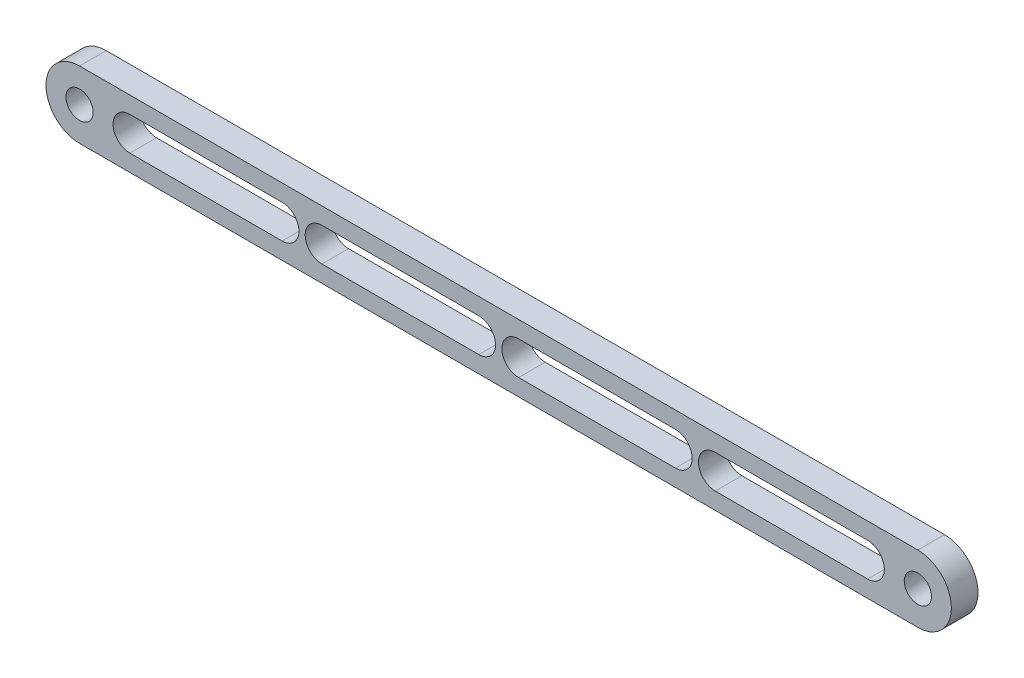
from build123d import *

# Parameters (mm, degrees)
SKETCH1_R           = 3.25
BOSS_EXTRUDE1_DEPTH = 6.35


with BuildPart() as part:
    # Sketch1 → Boss-Extrude1 (new body)
    with BuildSketch(Plane.XY.offset(6.35)):
        with BuildLine():
            Line((200, 8), (0, 8))
            ThreePointArc((0, 8), (-8, 0), (0, -8))
            Line((0, -8), (200, -8))
            ThreePointArc((200, -8), (208, 0), (200, 8))
        make_face()
        with Locations((200, 0)):
            Circle(SKETCH1_R, mode=Mode.SUBTRACT)
        Circle(SKETCH1_R, mode=Mode.SUBTRACT)
        with BuildLine():
            Line((104.75, 4), (142.160898385, 4))
            ThreePointArc((142.160898385, 4), (146.160898385, 0), (142.160898385, -4))
            Line((142.160898385, -4), (104.75, -4))
            ThreePointArc((104.75, -4), (100.75, 0), (104.75, 4))
        make_face(mode=Mode.SUBTRACT)
        with BuildLine():
            Line((12, 4), (48.339101615, 4))
            ThreePointArc((48.339101615, 4), (52.339101615, 0), (48.339101615, -4))
            Line((48.339101615, -4), (12, -4))
            ThreePointArc((12, -4), (8, 0), (12, 4))
        make_face(mode=Mode.SUBTRACT)
        with BuildLine():
            Line((57.839101615, 4), (95.25, 4))
            ThreePointArc((95.25, 4), (99.25, 0), (95.25, -4))
            Line((95.25, -4), (57.839101615, -4))
            ThreePointArc((57.839101615, -4), (53.839101615, 0), (57.839101615, 4))
        make_face(mode=Mode.SUBTRACT)
        with BuildLine():
            Line((188, -4), (151.660898385, -4))
            ThreePointArc((151.660898385, -4), (147.660898385, 0), (151.660898385, 4))
            Line((151.660898385, 4), (188, 4))
            ThreePointArc((188, 4), (192, 0), (188, -4))
        make_face(mode=Mode.SUBTRACT)
    extrude(amount=-BOSS_EXTRUDE1_DEPTH)


solid = part.part
